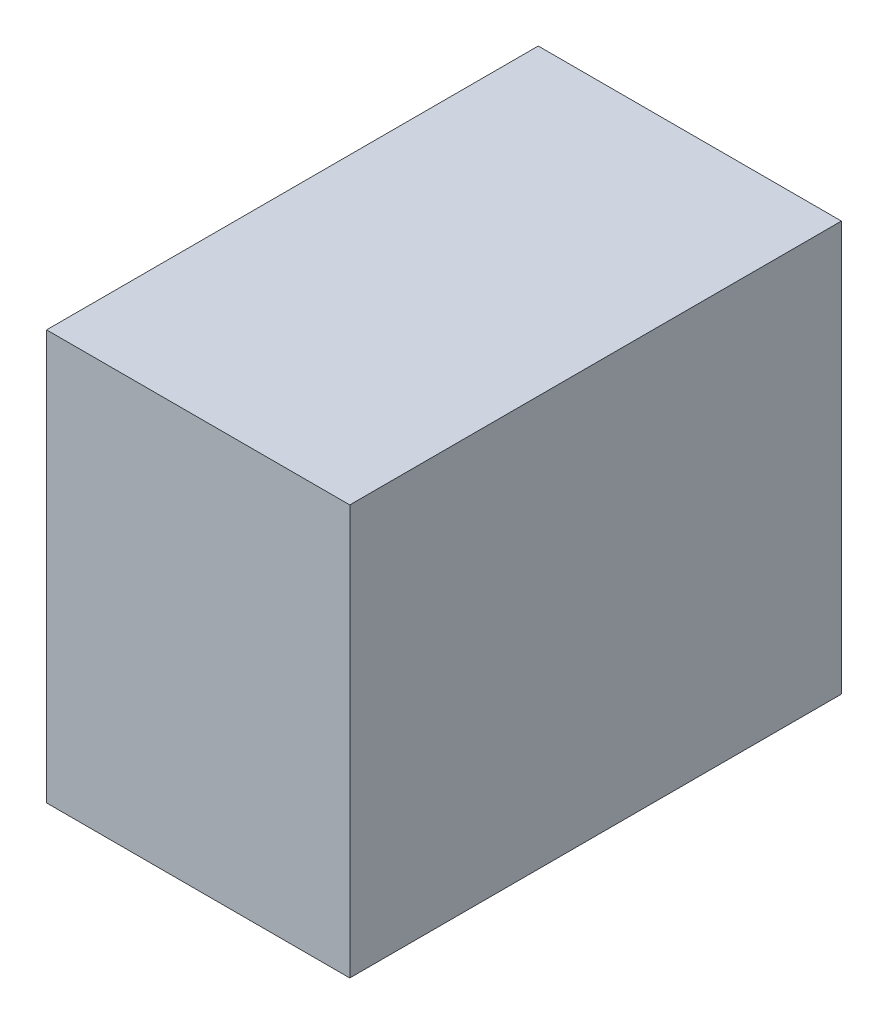
from build123d import *

# Parameters (mm, degrees)
SKETCH1_W           = 939.8
SKETCH1_H           = 1524
BOSS_EXTRUDE1_DEPTH = 635


with BuildPart() as part:
    # Sketch1 → Boss-Extrude1 (new body, symmetric)
    with BuildSketch(Plane(origin=(0, 0, 0), x_dir=(1, 0, 0), z_dir=(0, 1, 0))):
        Rectangle(SKETCH1_W, SKETCH1_H)
    extrude(amount=BOSS_EXTRUDE1_DEPTH, both=True)


solid = part.part
